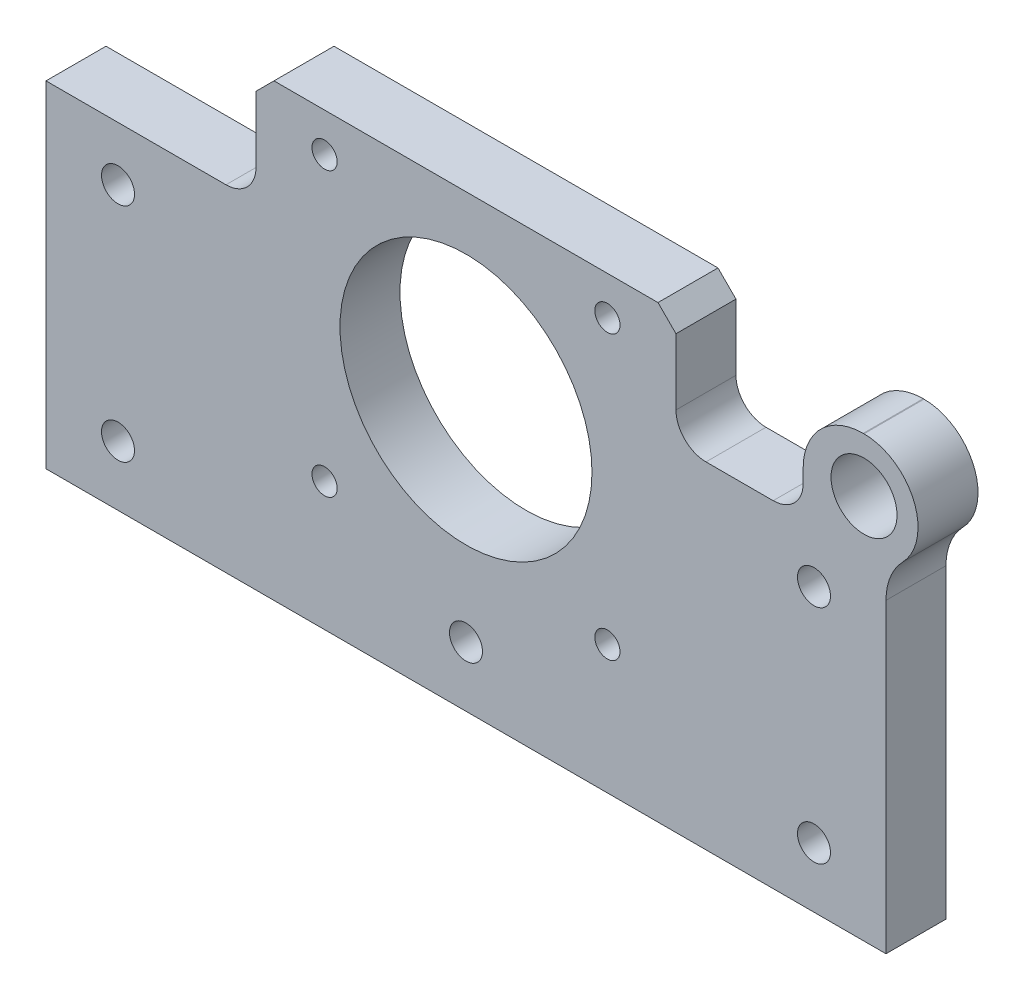
from build123d import *

# Parameters (mm, degrees)
EXTRUDE1_DEPTH                                      = 10
M5_TAPPED_HOLE1_D                                   = 4.2
CUT_EXTRUDE1_REACH                                  = 12
SKETCH4_R                                           = 21
CHAMFER1_SIZE                                       = 3
CBORE_FOR_M5_HEX_SOCKET_HEAD_CAP_SCREW1_D           = 5.5
CBORE_FOR_M5_HEX_SOCKET_HEAD_CAP_SCREW1_CBORE_D     = 10
CBORE_FOR_M5_HEX_SOCKET_HEAD_CAP_SCREW1_CBORE_DEPTH = 5.4
EXTRUDE2_DEPTH                                      = 10
FILLET3_R                                           = 10
FILLET4_R                                           = 5
M12X1_0_TAPPED_HOLE2_D                              = 11
M12X1_0_TAPPED_HOLE1_D                              = 11


with BuildPart() as part:
    # Sketch1 → Extrude1 (new body)
    with BuildSketch(Plane.XY):
        Polygon((35, 56), (70, 56), (70, 0), (-70, 0), (-70, 56), (-35, 56), (-35, 75), (35, 75), align=None)
    extrude(amount=EXTRUDE1_DEPTH)

    # M5 Tapped Hole1 (through all)
    with Locations(Plane(origin=(0, 0, 0), x_dir=(-1, 0, 0), z_dir=(0, 0, -1))):
        with Locations((-23.57, 68.57), (23.57, 68.57), (-23.57, 21.43), (23.57, 21.43)):
            Hole(M5_TAPPED_HOLE1_D / 2)

    # Sketch4 → Cut-Extrude1 (cut, up to next)
    with BuildSketch(Plane.XY.offset(10), mode=Mode.PRIVATE) as cut_extrude1_sk1:
        with Locations((0, 45)):
            Circle(SKETCH4_R)
    cut_extrude1_tool1 = extrude(cut_extrude1_sk1.sketch, amount=-CUT_EXTRUDE1_REACH, mode=Mode.PRIVATE) & part.part
    add(cut_extrude1_tool1.solids().sort_by_distance((0, 45, 10))[0], mode=Mode.SUBTRACT)

    # Chamfer1
    chamfer1_edges = [part.edges().sort_by_distance(p)[0] for p in [
        (-35, 75, 5),
        (35, 75, 5),
    ]]
    chamfer(chamfer1_edges, length=CHAMFER1_SIZE)

    # CBORE for M5 Hex Socket Head Cap Screw1 (through all)
    with Locations(Plane(origin=(0, 0, 0), x_dir=(-1, 0, 0), z_dir=(0, 0, -1))):
        with Locations((-58, 10), (0, 10), (58, 10), (58, 47), (-58, 47)):
            CounterBoreHole(CBORE_FOR_M5_HEX_SOCKET_HEAD_CAP_SCREW1_D / 2, CBORE_FOR_M5_HEX_SOCKET_HEAD_CAP_SCREW1_CBORE_D / 2, CBORE_FOR_M5_HEX_SOCKET_HEAD_CAP_SCREW1_CBORE_DEPTH)

    # Sketch7 → Extrude2 (add)
    with BuildSketch(Plane(origin=(0, 0, 0), x_dir=(-1, 0, 0), z_dir=(0, 0, -1))):
        with BuildLine():
            Line((-66.341582795, 73.222893867), (-56.19763933, 73.222893867))
            Line((-56.19763933, 73.222893867), (-56.19763933, 56))
            Line((-56.19763933, 56), (-70, 56))
            ThreePointArc((-70, 56), (-75.145162885, 66.092914615), (-66.341582795, 73.222893867))
        make_face()
    extrude(amount=-EXTRUDE2_DEPTH)

    # Fillet3
    fillet3_edges = [part.edges().sort_by_distance(p)[0] for p in [
        (56.19763933, 73.222893867, 5),
        (70, 56, 5),
    ]]
    fillet(fillet3_edges, radius=FILLET3_R)

    # Fillet4
    fillet4_edges = [part.edges().sort_by_distance(p)[0] for p in [
        (56.19763933, 56, 5),
        (-35, 56, 5),
        (35, 56, 5),
    ]]
    fillet(fillet4_edges, radius=FILLET4_R)

    # M12x1.0 Tapped Hole2 (through all)
    with Locations(Plane(origin=(0, 0, 0), x_dir=(-1, 0, 0), z_dir=(0, 0, -1))):
        with Locations((-66.341582795, 64.222893867)):
            Hole(M12X1_0_TAPPED_HOLE2_D / 2)

    # M12x1.0 Tapped Hole1 (through all)
    with Locations(Plane(origin=(0, 0, 0), x_dir=(-1, 0, 0), z_dir=(0, 0, -1))):
        with Locations((-66.341582795, 64.222893867)):
            Hole(M12X1_0_TAPPED_HOLE1_D / 2)


solid = part.part
